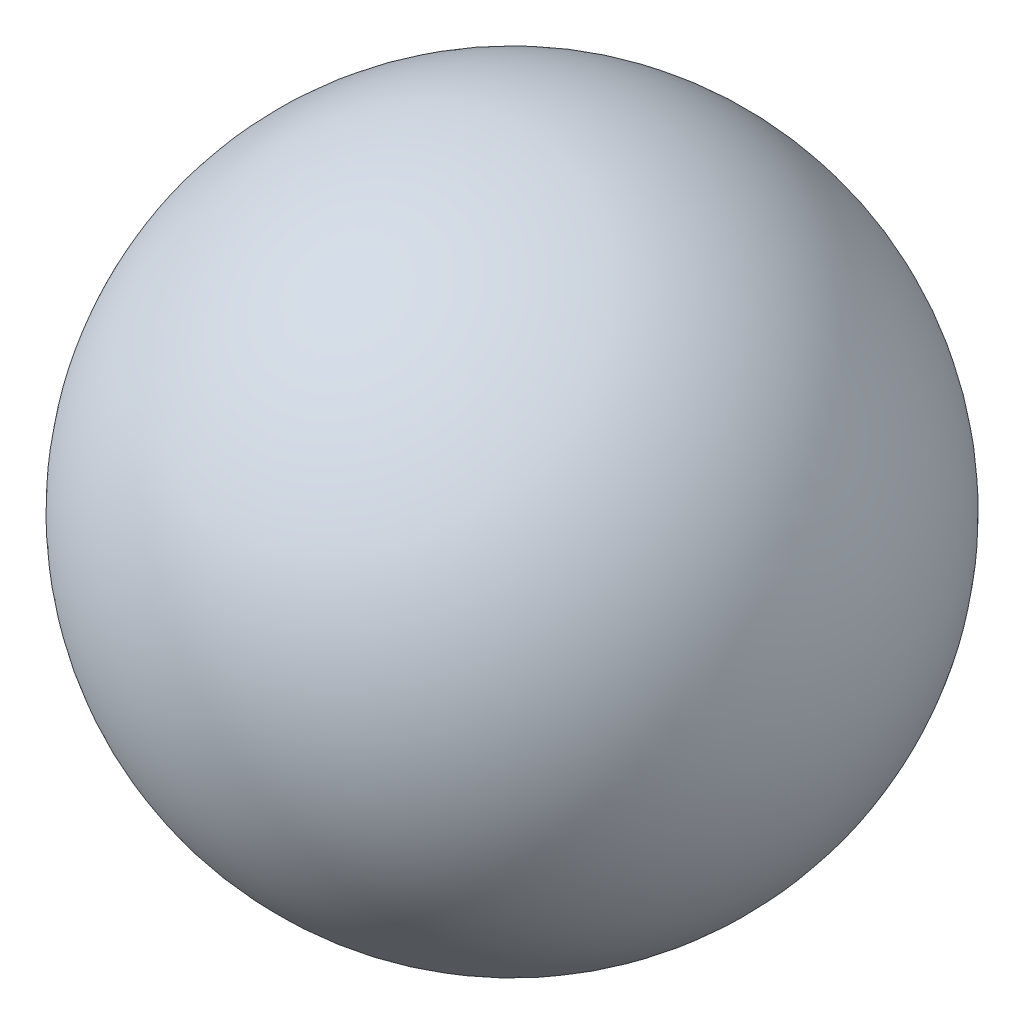
from build123d import *


with BuildPart() as part:
    # Sketch1 → Revolve1 (revolve)
    with BuildSketch(Plane.XY.offset(1.62233922)):
        with BuildLine():
            Line((3.643046711, -2.5), (6.343046711, -2.5))
            ThreePointArc((6.343046711, -2.5), (4.993046711, -1.15), (3.643046711, -2.5))
        make_face()
    revolve(axis=Axis((3.643046711, -2.5, 1.62233922), (1, 0, 0)))


solid = part.part
